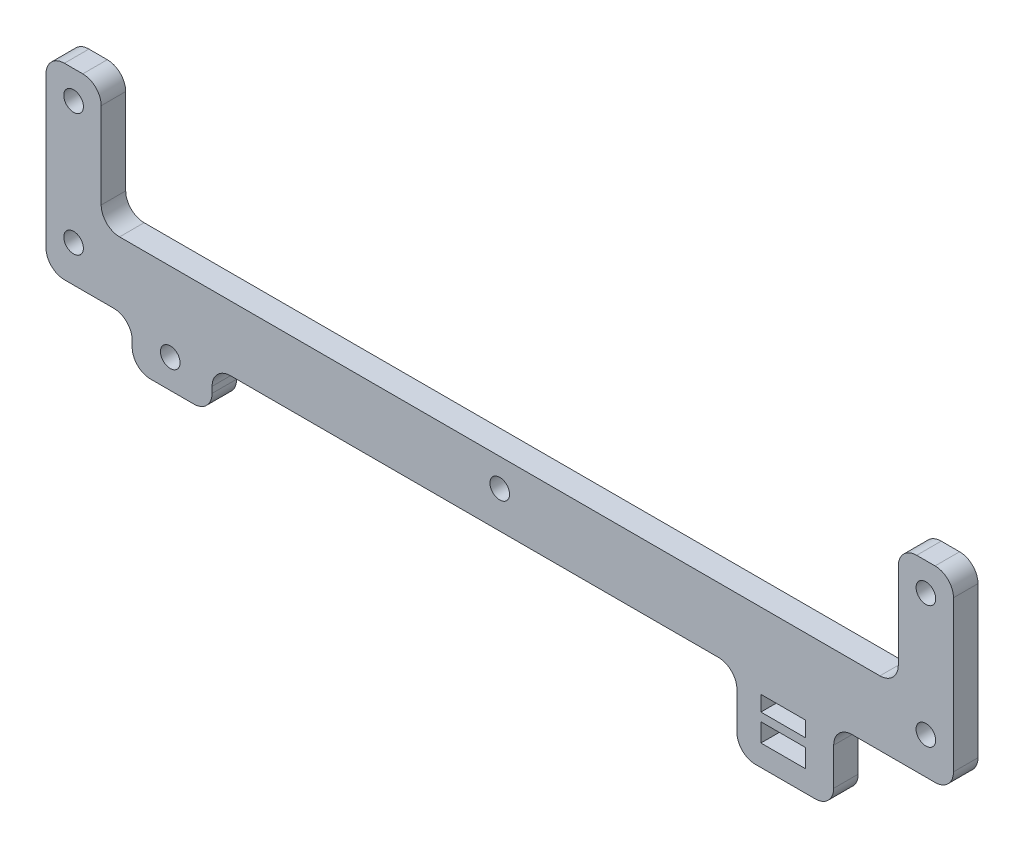
from build123d import *

# Parameters (mm, degrees)
ESBO_O1_W                = 7.305190172
ESBO_O1_H                = 2.5
ESBO_O1_H_2              = 3
RESSALTO_EXTRUS_O1_DEPTH = 4
CUT_EXTRUDE1_DEPTH       = 10
FURO_COM_FOLGA_DE_M31_D  = 3.2
FILLET1_R                = 3


with BuildPart() as part:
    # Esboço1 → Ressalto-extrusão1 (new body)
    with BuildSketch(Plane.XY):
        with BuildLine():
            Line((-49.295269139, -236.354481491), (30.295730877, -236.354481491))
            ThreePointArc((30.295730877, -236.354481491), (32.417051221, -237.233161147), (33.295730877, -239.354481491))
            Line((33.295730877, -239.354481491), (33.295730877, -245.447951064))
            ThreePointArc((33.295730877, -245.447951064), (34.174410534, -247.569271408), (36.295730877, -248.447951064))
            Line((36.295730877, -248.447951064), (46.077297056, -248.447951064))
            ThreePointArc((46.077297056, -248.447951064), (48.198617399, -247.569271408), (49.077297056, -245.447951064))
            Line((49.077297056, -245.447951064), (49.077297056, -239.354481491))
            ThreePointArc((49.077297056, -239.354481491), (49.955976712, -237.233161147), (52.077297056, -236.354481491))
            Line((52.077297056, -236.354481491), (68.643919436, -236.354481491))
            ThreePointArc((68.643919436, -236.354481491), (70.765239779, -235.475801834), (71.643919436, -233.354481491))
            Line((71.643919436, -233.354481491), (71.643919436, -231.207792375))
            Line((71.643919436, -231.207792375), (84.613919436, -231.207792375))
            Line((84.613919436, -231.207792375), (84.613919436, -65.265257908))
            Line((84.613919436, -65.265257908), (71.643919436, -65.265257908))
            Line((71.643919436, -65.265257908), (71.643919436, -47.354481491))
            ThreePointArc((71.643919436, -47.354481491), (70.765239779, -45.233161147), (68.643919436, -44.354481491))
            Line((68.643919436, -44.354481491), (-79.423286283, -44.354481491))
            ThreePointArc((-79.423286283, -44.354481491), (-81.544606627, -45.233161147), (-82.423286283, -47.354481491))
            Line((-82.423286283, -47.354481491), (-82.423286283, -65.265257908))
            Line((-82.423286283, -65.265257908), (-99.449266915, -65.265257908))
            Line((-99.449266915, -65.265257908), (-99.449266915, -233.354481491))
            ThreePointArc((-99.449266915, -233.354481491), (-98.570587259, -235.475801834), (-96.449266915, -236.354481491))
            Line((-96.449266915, -236.354481491), (-68.333570548, -236.354481491))
            ThreePointArc((-68.333570548, -236.354481491), (-66.212250205, -237.233161147), (-65.333570548, -239.354481491))
            Line((-65.333570548, -239.354481491), (-65.333570548, -240.354481491))
            ThreePointArc((-65.333570548, -240.354481491), (-64.454890892, -242.475801834), (-62.333570548, -243.354481491))
            Line((-62.333570548, -243.354481491), (-55.295269139, -243.354481491))
            ThreePointArc((-55.295269139, -243.354481491), (-53.173948795, -242.475801834), (-52.295269139, -240.354481491))
            Line((-52.295269139, -240.354481491), (-52.295269139, -239.354481491))
            ThreePointArc((-52.295269139, -239.354481491), (-51.416589482, -237.233161147), (-49.295269139, -236.354481491))
        make_face()
        with Locations((40.863663265, -239.358820259)):
            Rectangle(ESBO_O1_W, ESBO_O1_H, mode=Mode.SUBTRACT)
        with Locations((40.863663265, -243.481650875)):
            Rectangle(ESBO_O1_W, ESBO_O1_H_2, mode=Mode.SUBTRACT)
        with Locations((40.863663265, -51.350142723)):
            Rectangle(ESBO_O1_W, ESBO_O1_H, mode=Mode.SUBTRACT)
        with Locations((40.863663265, -47.227312107)):
            Rectangle(ESBO_O1_W, ESBO_O1_H_2, mode=Mode.SUBTRACT)
    extrude(amount=RESSALTO_EXTRUS_O1_DEPTH)

    # Sketch1 → Cut-Extrude1 (cut)
    with BuildSketch(Plane.XY.offset(4)):
        with BuildLine():
            Line((-79.386080564, -236.354481491), (-79.386080564, -228.792861815))
            Line((-79.386080564, -228.792861815), (-79.386080564, -205.765971774))
            Line((-79.386080564, -205.765971774), (-70.386080564, -205.765971774))
            Line((-70.386080564, -205.765971774), (-70.386080564, -225.792861815))
            Line((-70.386080564, -225.792861815), (59.613919436, -225.792861815))
            Line((59.613919436, -225.792861815), (59.613919436, -205.765971774))
            Line((59.613919436, -205.765971774), (68.613919436, -205.765971774))
            Line((68.613919436, -205.765971774), (68.613919436, -228.792861815))
            Line((68.613919436, -228.792861815), (68.613919436, -236.354481491))
            Line((68.613919436, -236.354481491), (68.643919436, -236.354481491))
            ThreePointArc((68.643919436, -236.354481491), (70.765239779, -235.475801834), (71.643919436, -233.354481491))
            Line((71.643919436, -233.354481491), (71.643919436, -231.207792375))
            Line((71.643919436, -231.207792375), (84.613919436, -231.207792375))
            Line((84.613919436, -231.207792375), (84.613919436, -65.265257908))
            Line((84.613919436, -65.265257908), (71.643919436, -65.265257908))
            Line((71.643919436, -65.265257908), (71.643919436, -47.354481491))
            ThreePointArc((71.643919436, -47.354481491), (70.765239779, -45.233161147), (68.643919436, -44.354481491))
            Line((68.643919436, -44.354481491), (-79.423286283, -44.354481491))
            ThreePointArc((-79.423286283, -44.354481491), (-81.544606627, -45.233161147), (-82.423286283, -47.354481491))
            Line((-82.423286283, -47.354481491), (-82.423286283, -65.265257908))
            Line((-82.423286283, -65.265257908), (-99.449266915, -65.265257908))
            Line((-99.449266915, -65.265257908), (-99.449266915, -233.354481491))
            ThreePointArc((-99.449266915, -233.354481491), (-98.570587259, -235.475801834), (-96.449266915, -236.354481491))
            Line((-96.449266915, -236.354481491), (-79.386080564, -236.354481491))
        make_face()
    extrude(amount=-CUT_EXTRUDE1_DEPTH, mode=Mode.SUBTRACT)

    # Furo com folga de M31 (through all)
    with Locations(Plane.XY.offset(4)):
        with Locations((-74.886080564, -50.354481491), (64.113919436, -230.354481491), (64.113919436, -50.354481491), (-74.886080564, -230.354481491), (-59.12185492, -47.477548601), (-5.386080564, -50.354481491), (-59.12185492, -238.651414381), (-5.386080564, -230.354481491), (64.113919436, -210.354481491), (-74.886080564, -210.354481491)):
            Hole(FURO_COM_FOLGA_DE_M31_D / 2)

    # Fillet1
    fillet1_edges = [part.edges().sort_by_distance(p)[0] for p in [
        (-79.386080564, -236.354481491, 2),
        (68.613919436, -205.765971774, 2),
        (59.613919436, -205.765971774, 2),
        (59.613919436, -225.792861815, 2),
        (-70.386080564, -225.792861815, 2),
        (-70.386080564, -205.765971774, 2),
        (-79.386080564, -205.765971774, 2),
        (68.613919436, -236.354481491, 2),
    ]]
    fillet(fillet1_edges, radius=FILLET1_R)


solid = part.part
